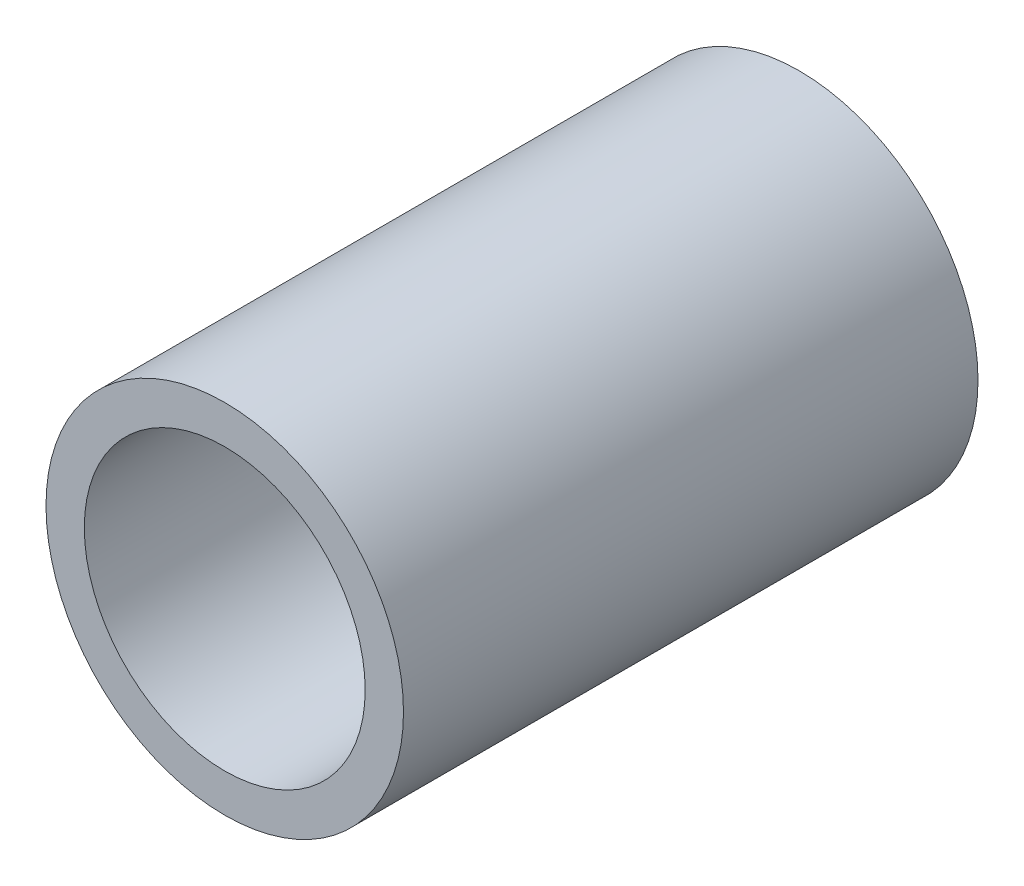
from build123d import *

# Parameters (mm, degrees)
SKETCH_1_R          = 14
EXTRUDE_1_DEPTH     = 45
SKETCH_5_R          = 11
CUT_EXTRUDE_3_DEPTH = 31


with BuildPart() as part:
    # Эскиз1 → Бобышка-Вытянуть1 (new body)
    with BuildSketch(Plane.XY):
        Circle(SKETCH_1_R)
    extrude(amount=EXTRUDE_1_DEPTH)

    # Эскиз5 → Вырез-Вытянуть3 (cut)
    with BuildSketch(Plane.XY.offset(45)):
        Circle(SKETCH_5_R)
    extrude(amount=-CUT_EXTRUDE_3_DEPTH, mode=Mode.SUBTRACT)


solid = part.part
